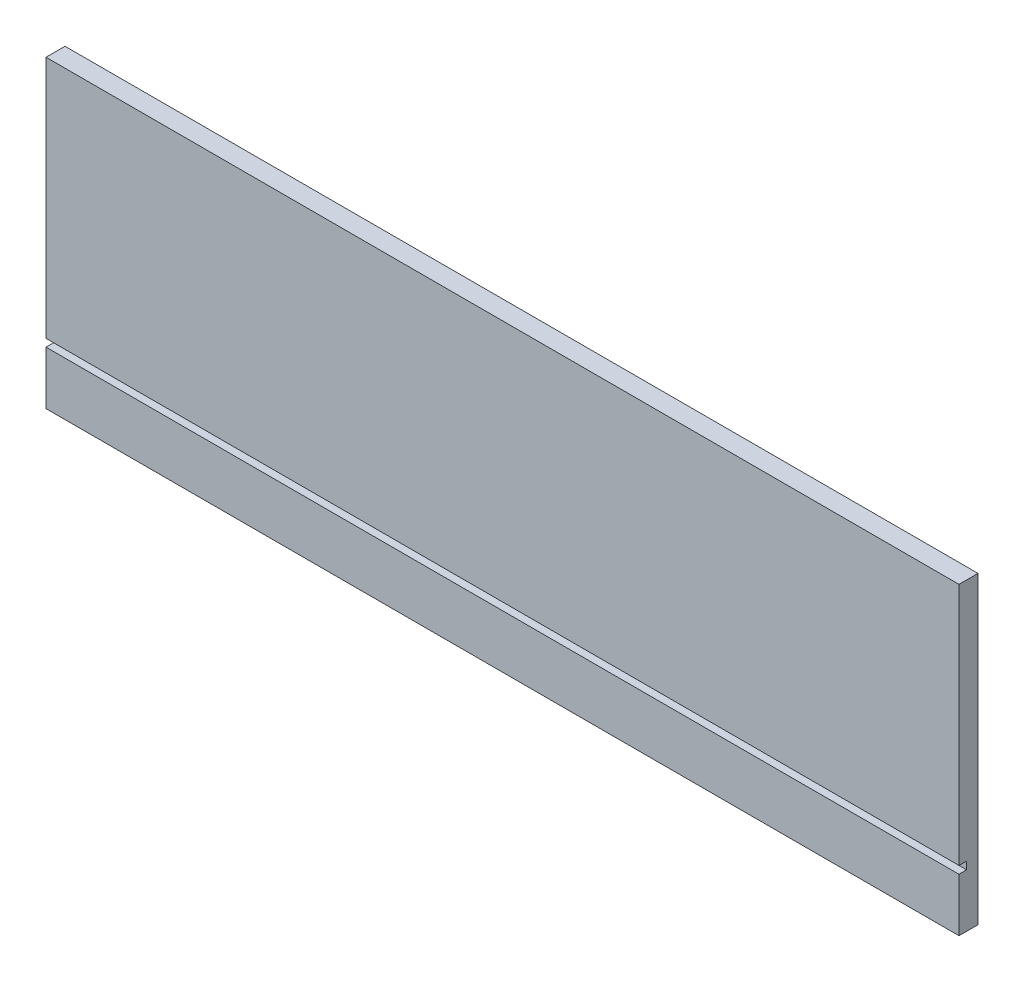
from build123d import *

# Parameters (mm, degrees)
SKETCH1_W           = 762
SKETCH1_H           = 254
BOSS_EXTRUDE1_DEPTH = 15.875
SKETCH2_W           = 6.35
SKETCH2_H           = 6.35
CUT_EXTRUDE1_DEPTH  = 763


with BuildPart() as part:
    # Sketch1 → Boss-Extrude1 (new body)
    with BuildSketch(Plane.XY):
        with Locations((381, 127)):
            Rectangle(SKETCH1_W, SKETCH1_H)
    extrude(amount=BOSS_EXTRUDE1_DEPTH)

    # Sketch2 → Cut-Extrude1 (cut, through all)
    with BuildSketch(Plane(origin=(762, 0, 0), x_dir=(0, 0, -1), z_dir=(1, 0, 0))):
        with Locations((-12.7, 47.625)):
            Rectangle(SKETCH2_W, SKETCH2_H)
    extrude(amount=-CUT_EXTRUDE1_DEPTH, mode=Mode.SUBTRACT)


solid = part.part
